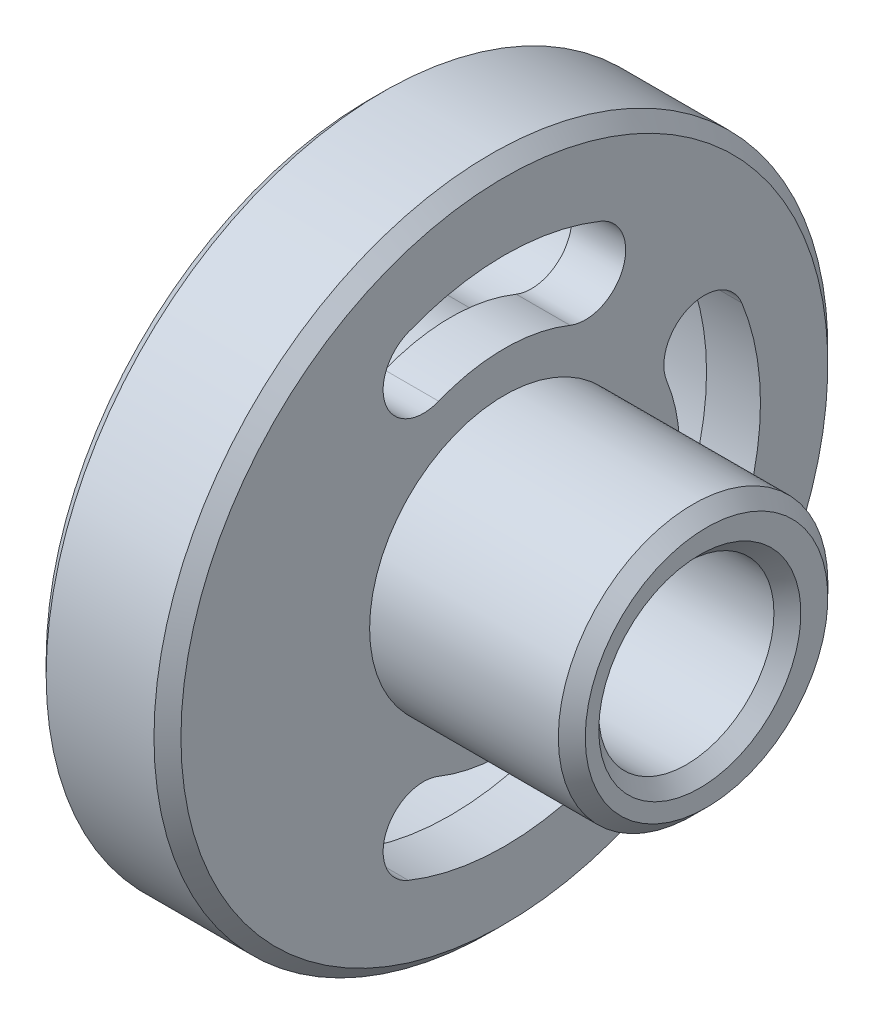
from build123d import *

# Parameters (mm, degrees)
CUT_EXTRUDE_2_DEPTH = 6
CUT_EXTRUDE_3_DEPTH = 26
SKETCH_3_R          = 6.5
CUT_EXTRUDE_4_DEPTH = 26
CHAMFER_1_SIZE      = 1
CHAMFER_3_SIZE      = 1


with BuildPart() as part:
    # Эскиз1 → Повернуть1 (revolve)
    with BuildSketch(Plane.XY):
        Polygon((0, 0), (0, 24), (1, 25), (9, 25), (10, 24), (10, 10), (24, 10), (25, 9), (25, 0), align=None)
    revolve(axis=Axis((0, 0, 0), (1, 0, 0)))

    # Эскиз4 → Вырез-Вытянуть2 (cut)
    with BuildSketch(Plane.ZY):
        with BuildLine():
            ThreePointArc((7.875, 19.467521029), (0, 21), (-7.875, 19.467521029))
            ThreePointArc((-7.875, 19.467521029), (-10.635124054, 12.957396974), (-4.125, 10.19727292))
            ThreePointArc((-4.125, 10.19727292), (0, 11), (4.125, 10.19727292))
            ThreePointArc((4.125, 10.19727292), (10.635124054, 12.957396974), (7.875, 19.467521029))
        make_face()
        with BuildLine():
            ThreePointArc((-10.19727292, 4.125), (-11, 0), (-10.19727292, -4.125))
            ThreePointArc((-10.19727292, -4.125), (-12.957396974, -10.635124054), (-19.467521029, -7.875))
            ThreePointArc((-19.467521029, -7.875), (-21, 0), (-19.467521029, 7.875))
            ThreePointArc((-19.467521029, 7.875), (-12.957396974, 10.635124054), (-10.19727292, 4.125))
        make_face()
        with BuildLine():
            ThreePointArc((-4.125, -10.19727292), (0, -11), (4.125, -10.19727292))
            ThreePointArc((4.125, -10.19727292), (10.635124054, -12.957396974), (7.875, -19.467521029))
            ThreePointArc((7.875, -19.467521029), (0, -21), (-7.875, -19.467521029))
            ThreePointArc((-7.875, -19.467521029), (-10.635124054, -12.957396974), (-4.125, -10.19727292))
        make_face()
    extrude(amount=-CUT_EXTRUDE_2_DEPTH, mode=Mode.SUBTRACT)

    # Эскиз5 → Вырез-Вытянуть3 (cut, through all)
    with BuildSketch(Plane.ZY):
        with BuildLine():
            ThreePointArc((7.125, 17.613471407), (0, 19), (-7.125, 17.613471407))
            ThreePointArc((-7.125, 17.613471407), (-8.781074433, 13.707396974), (-4.875, 12.051322542))
            ThreePointArc((-4.875, 12.051322542), (0, 13), (4.875, 12.051322542))
            ThreePointArc((4.875, 12.051322542), (8.781074433, 13.707396974), (7.125, 17.613471407))
        make_face()
        with BuildLine():
            ThreePointArc((-12.051322542, 4.875), (-13, 0), (-12.051322542, -4.875))
            ThreePointArc((-12.051322542, -4.875), (-13.707396974, -8.781074433), (-17.613471407, -7.125))
            ThreePointArc((-17.613471407, -7.125), (-19, 0), (-17.613471407, 7.125))
            ThreePointArc((-17.613471407, 7.125), (-13.707396974, 8.781074433), (-12.051322542, 4.875))
        make_face()
        with BuildLine():
            ThreePointArc((-4.875, -12.051322542), (0, -13), (4.875, -12.051322542))
            ThreePointArc((4.875, -12.051322542), (8.781074433, -13.707396974), (7.125, -17.613471407))
            ThreePointArc((7.125, -17.613471407), (0, -19), (-7.125, -17.613471407))
            ThreePointArc((-7.125, -17.613471407), (-8.781074433, -13.707396974), (-4.875, -12.051322542))
        make_face()
    extrude(amount=-CUT_EXTRUDE_3_DEPTH, mode=Mode.SUBTRACT)

    # Эскиз3 → Вырез-Вытянуть4 (cut, through all)
    with BuildSketch(Plane(origin=(25, 0, 0), x_dir=(0, 0, -1), z_dir=(1, 0, 0))):
        with Locations((-0.5, 0)):
            Circle(SKETCH_3_R)
    extrude(amount=-CUT_EXTRUDE_4_DEPTH, mode=Mode.SUBTRACT)

    # Фаска1
    chamfer_1_edges = [part.edges().sort_by_distance(p)[0] for p in [
        (25, 0, 7),
    ]]
    chamfer(chamfer_1_edges, length=CHAMFER_1_SIZE)

    # Фаска3
    chamfer_3_edges = [part.edges().sort_by_distance(p)[0] for p in [
        (0, 0, 7),
    ]]
    chamfer(chamfer_3_edges, length=CHAMFER_3_SIZE)


solid = part.part
